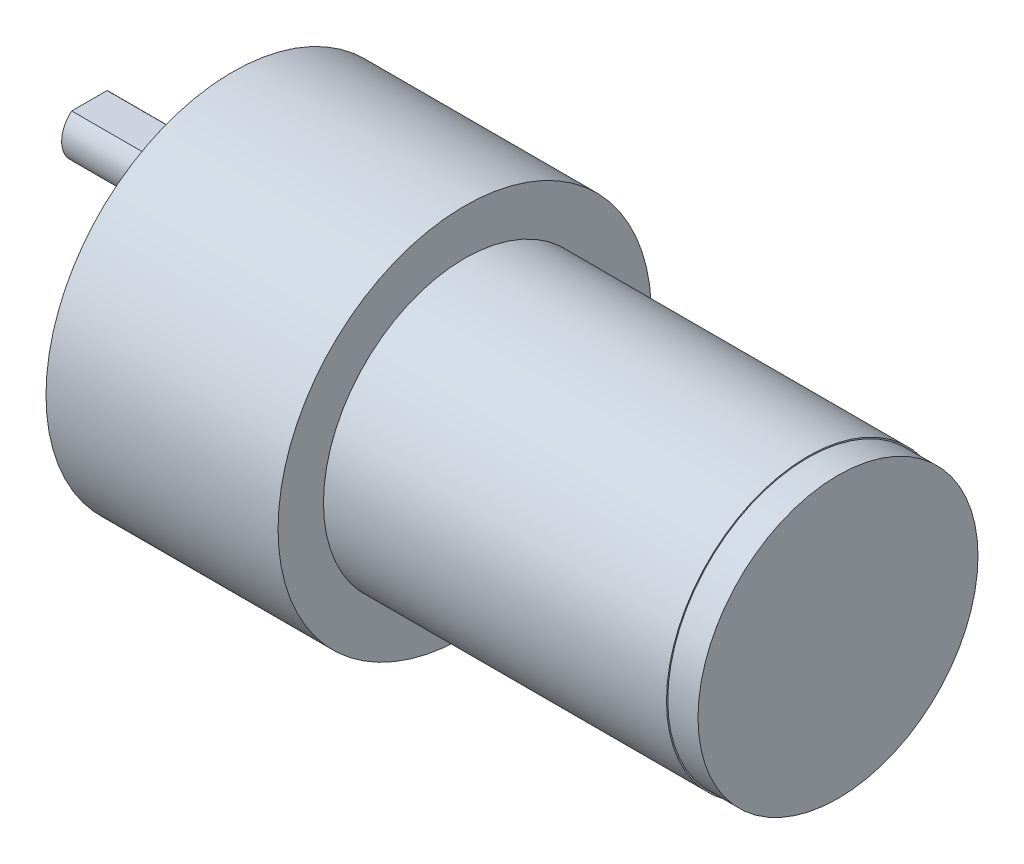
from build123d import *

# Parameters (mm, degrees)
SKETCH1_R           = 14
BOSS_EXTRUDE1_DEPTH = 34
SKETCH2_R           = 18.5
BOSS_EXTRUDE2_DEPTH = 23
SKETCH3_R           = 6
BOSS_EXTRUDE3_DEPTH = 6
SKETCH5_R           = 2.75
BOSS_EXTRUDE4_DEPTH = 15
CUT_EXTRUDE1_DEPTH  = 12
SKETCH7_R           = 13.875
BOSS_EXTRUDE5_DEPTH = 3


with BuildPart() as part:
    # Sketch1 → Boss-Extrude1 (new body)
    with BuildSketch(Plane(origin=(0, 0, 0), x_dir=(0, 0, -1), z_dir=(1, 0, 0))):
        Circle(SKETCH1_R)
    extrude(amount=-BOSS_EXTRUDE1_DEPTH)

    # Sketch2 → Boss-Extrude2 (add)
    with BuildSketch(Plane.ZY.offset(34)):
        Circle(SKETCH2_R)
    extrude(amount=BOSS_EXTRUDE2_DEPTH)

    # Sketch3 → Boss-Extrude3 (add)
    with BuildSketch(Plane.ZY.offset(57)):
        with Locations((-6.8, 0)):
            Circle(SKETCH3_R)
    extrude(amount=BOSS_EXTRUDE3_DEPTH)

    # Sketch5 → Boss-Extrude4 (add)
    with BuildSketch(Plane.ZY.offset(63)):
        with Locations((-6.8, 0)):
            Circle(SKETCH5_R)
    extrude(amount=BOSS_EXTRUDE4_DEPTH)

    # Sketch6 → Cut-Extrude1 (cut)
    with BuildSketch(Plane.ZY.offset(78)):
        with BuildLine():
            Line((-8.55, 2.121320344), (-5.05, 2.121320344))
            ThreePointArc((-5.05, 2.121320344), (-6.8, 2.75), (-8.55, 2.121320344))
        make_face()
    extrude(amount=-CUT_EXTRUDE1_DEPTH, mode=Mode.SUBTRACT)

    # Sketch7 → Boss-Extrude5 (add)
    with BuildSketch(Plane(origin=(0, 0, 0), x_dir=(0, 0, -1), z_dir=(1, 0, 0))):
        Circle(SKETCH7_R)
    extrude(amount=BOSS_EXTRUDE5_DEPTH)


solid = part.part
